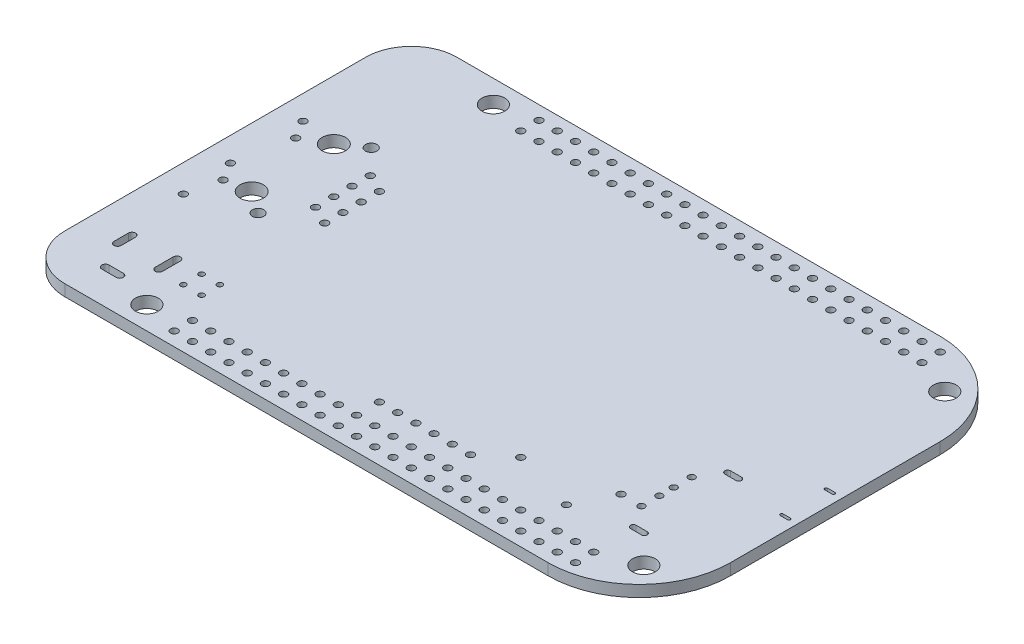
from build123d import *

# Parameters (mm, degrees)
SKETCH2_W                         = 86.36
SKETCH2_H                         = 54.61
MAIN_BOARD_DEPTH                  = 0.79375
SKETCH3_R                         = 1.5875
BOARD_MOUNTING_HOLES_DEPTH        = 2.5875
SKETCH4_R                         = 0.508
SKETCH4_R_2                       = 0.8001
SKETCH4_R_3                       = 1.6256
P5_ETHERNET_CONNECTOR_HOLES_DEPTH = 2.5875
SKETCH5_R                         = 0.45999908
P3_USB_HOST_DEPTH                 = 2.5875
P6_HDMI_DEPTH                     = 2.5875
SKETCH7_R                         = 0.50999898
P9_IDC_EXPANSION_PORT_DEPTH       = 2.5875
SKETCH8_R                         = 0.50999898
P8_IDC_EXPANSION_PORT_DEPTH       = 2.5875
SKETCH9_R                         = 0.508
TP1_TEST_POINT_1_DEPTH            = 2.5875
SKETCH10_R                        = 0.508
TP4_TEST_POINT_4_DEPTH            = 2.5875
SKETCH11_R                        = 0.508
RT1_CAPACITOR_DEPTH               = 2.5875
SKETCH12_R                        = 0.508
J1_DEBUG_PORT_DEPTH               = 2.5875
P1_POWER_PLUG_DEPTH               = 2.5875
SKETCH14_R                        = 0.381
TP6_BATTERY_DEPTH                 = 2.5875
SKETCH15_R                        = 0.381
TP8_BATTERY_DEPTH                 = 2.5875
SKETCH16_R                        = 0.381
TP5_BATTERY_DEPTH                 = 2.5875
SKETCH18_R                        = 0.381
TP7_BATTERY_DEPTH                 = 2.5875
FILLET1_R                         = 6.35
FILLET2_R                         = 12.7


with BuildPart() as part:
    # Sketch2 → Main Board (new body, symmetric)
    with BuildSketch(Plane(origin=(0, 0, 0), x_dir=(1, 0, 0), z_dir=(0, 1, 0))):
        Rectangle(SKETCH2_W, SKETCH2_H)
    extrude(amount=MAIN_BOARD_DEPTH, both=True)

    # Sketch3 → Board Mounting Holes (cut, through all)
    with BuildSketch(Plane.XZ.offset(0.79375)):
        with Locations((37.465, 20.955)):
            Circle(SKETCH3_R)
        with Locations((37.465, -20.955)):
            Circle(SKETCH3_R)
        with Locations((-28.575, -24.13)):
            Circle(SKETCH3_R)
        with Locations((-28.575, 24.13)):
            Circle(SKETCH3_R)
    extrude(amount=-BOARD_MOUNTING_HOLES_DEPTH, mode=Mode.SUBTRACT)

    # Sketch4 → P5 - Ethernet Connector Holes (cut, through all)
    with BuildSketch(Plane.XZ.offset(0.79375)):
        with Locations((-38.3032, 3.7846)):
            Circle(SKETCH4_R)
        with Locations((-39.8272, 1.2446)):
            Circle(SKETCH4_R)
        with Locations((-38.3032, -6.3246)):
            Circle(SKETCH4_R)
        with Locations((-39.8272, -8.8646)):
            Circle(SKETCH4_R)
        with Locations((-28.575, -6.985)):
            Circle(SKETCH4_R)
        with Locations((-28.575, -4.445)):
            Circle(SKETCH4_R)
        with Locations((-28.575, -1.905)):
            Circle(SKETCH4_R)
        with Locations((-28.575, 0.635)):
            Circle(SKETCH4_R)
        with Locations((-26.035, 1.905)):
            Circle(SKETCH4_R)
        with Locations((-26.035, -0.635)):
            Circle(SKETCH4_R)
        with Locations((-26.035, -3.175)):
            Circle(SKETCH4_R)
        with Locations((-26.035, -5.715)):
            Circle(SKETCH4_R)
        with Locations((-31.877, 5.334)):
            Circle(SKETCH4_R_2)
        with Locations((-34.925, 3.175)):
            Circle(SKETCH4_R_3)
        with Locations((-34.925, -8.255)):
            Circle(SKETCH4_R_3)
        with Locations((-31.877, -10.414)):
            Circle(SKETCH4_R_2)
    extrude(amount=-P5_ETHERNET_CONNECTOR_HOLES_DEPTH, mode=Mode.SUBTRACT)

    # Sketch5 → P3 - USB Host (cut, through all)
    with BuildSketch(Plane.XZ.offset(0.79375)):
        with Locations((30.16019114, 13.98778)):
            Circle(SKETCH5_R)
        with Locations((30.16019114, 11.48842)):
            Circle(SKETCH5_R)
        with Locations((30.16019114, 9.4869)):
            Circle(SKETCH5_R)
        with Locations((30.16019114, 6.98754)):
            Circle(SKETCH5_R)
        with BuildLine():
            Line((32.10037014, 17.45453456), (33.64037214, 17.45453456))
            ThreePointArc((33.64037214, 17.45453456), (34.03724714, 17.05765956), (33.64037214, 16.66078456))
            Line((33.64037214, 16.66078456), (32.10037014, 16.66078456))
            ThreePointArc((32.10037014, 16.66078456), (31.70349514, 17.05765956), (32.10037014, 17.45453456))
        make_face()
        with BuildLine():
            Line((32.10037014, 4.31453544), (33.64037214, 4.31453544))
            ThreePointArc((33.64037214, 4.31453544), (34.03724714, 3.91766044), (33.64037214, 3.52078544))
            Line((33.64037214, 3.52078544), (32.10037014, 3.52078544))
            ThreePointArc((32.10037014, 3.52078544), (31.70349514, 3.91766044), (32.10037014, 4.31453544))
        make_face()
    extrude(amount=-P3_USB_HOST_DEPTH, mode=Mode.SUBTRACT)

    # Sketch6 → P6 - HDMI (cut, through all)
    with BuildSketch(Plane.XZ.offset(0.79375)):
        with BuildLine():
            Line((40.962072, 5.4575075), (41.978072, 5.4575075))
            ThreePointArc((41.978072, 5.4575075), (42.1765095, 5.25907), (41.978072, 5.0606325))
            Line((41.978072, 5.0606325), (40.962072, 5.0606325))
            ThreePointArc((40.962072, 5.0606325), (40.7636345, 5.25907), (40.962072, 5.4575075))
        make_face()
        with BuildLine():
            Line((40.962072, -0.7426325), (41.978072, -0.7426325))
            ThreePointArc((41.978072, -0.7426325), (42.1765095, -0.94107), (41.978072, -1.1395075))
            Line((41.978072, -1.1395075), (40.962072, -1.1395075))
            ThreePointArc((40.962072, -1.1395075), (40.7636345, -0.94107), (40.962072, -0.7426325))
        make_face()
    extrude(amount=-P6_HDMI_DEPTH, mode=Mode.SUBTRACT)

    # Sketch7 → P9 - IDC Expansion Port (cut, through all)
    with BuildSketch(Plane.XZ.offset(0.79375)):
        with Locations((32.385, 25.4)):
            Circle(SKETCH7_R)
        with Locations((29.845, 25.4)):
            Circle(SKETCH7_R)
        with Locations((27.305, 25.4)):
            Circle(SKETCH7_R)
        with Locations((24.765, 25.4)):
            Circle(SKETCH7_R)
        with Locations((22.225, 25.4)):
            Circle(SKETCH7_R)
        with Locations((19.685, 25.4)):
            Circle(SKETCH7_R)
        with Locations((17.145, 25.4)):
            Circle(SKETCH7_R)
        with Locations((14.605, 25.4)):
            Circle(SKETCH7_R)
        with Locations((12.065, 25.4)):
            Circle(SKETCH7_R)
        with Locations((9.525, 25.4)):
            Circle(SKETCH7_R)
        with Locations((6.985, 25.4)):
            Circle(SKETCH7_R)
        with Locations((4.445, 25.4)):
            Circle(SKETCH7_R)
        with Locations((1.905, 25.4)):
            Circle(SKETCH7_R)
        with Locations((-0.635, 25.4)):
            Circle(SKETCH7_R)
        with Locations((-3.175, 25.4)):
            Circle(SKETCH7_R)
        with Locations((-5.715, 25.4)):
            Circle(SKETCH7_R)
        with Locations((-8.255, 25.4)):
            Circle(SKETCH7_R)
        with Locations((-10.795, 25.4)):
            Circle(SKETCH7_R)
        with Locations((-13.335, 25.4)):
            Circle(SKETCH7_R)
        with Locations((-15.875, 25.4)):
            Circle(SKETCH7_R)
        with Locations((-18.415, 25.4)):
            Circle(SKETCH7_R)
        with Locations((-20.955, 25.4)):
            Circle(SKETCH7_R)
        with Locations((-23.495, 25.4)):
            Circle(SKETCH7_R)
        with Locations((29.845, 22.86)):
            Circle(SKETCH7_R)
        with Locations((27.305, 22.86)):
            Circle(SKETCH7_R)
        with Locations((24.765, 22.86)):
            Circle(SKETCH7_R)
        with Locations((22.225, 22.86)):
            Circle(SKETCH7_R)
        with Locations((19.685, 22.86)):
            Circle(SKETCH7_R)
        with Locations((17.145, 22.86)):
            Circle(SKETCH7_R)
        with Locations((14.605, 22.86)):
            Circle(SKETCH7_R)
        with Locations((12.065, 22.86)):
            Circle(SKETCH7_R)
        with Locations((9.525, 22.86)):
            Circle(SKETCH7_R)
        with Locations((6.985, 22.86)):
            Circle(SKETCH7_R)
        with Locations((4.445, 22.86)):
            Circle(SKETCH7_R)
        with Locations((1.905, 22.86)):
            Circle(SKETCH7_R)
        with Locations((-0.635, 22.86)):
            Circle(SKETCH7_R)
        with Locations((-3.175, 22.86)):
            Circle(SKETCH7_R)
        with Locations((-5.715, 22.86)):
            Circle(SKETCH7_R)
        with Locations((-8.255, 22.86)):
            Circle(SKETCH7_R)
        with Locations((-10.795, 22.86)):
            Circle(SKETCH7_R)
        with Locations((-13.335, 22.86)):
            Circle(SKETCH7_R)
        with Locations((-15.875, 22.86)):
            Circle(SKETCH7_R)
        with Locations((-18.415, 22.86)):
            Circle(SKETCH7_R)
        with Locations((-20.955, 22.86)):
            Circle(SKETCH7_R)
        with Locations((-23.495, 22.86)):
            Circle(SKETCH7_R)
        with Locations((32.385, 22.86)):
            Circle(SKETCH7_R)
    extrude(amount=-P9_IDC_EXPANSION_PORT_DEPTH, mode=Mode.SUBTRACT)

    # Sketch8 → P8 - IDC Expansion Port (cut, through all)
    with BuildSketch(Plane.XZ.offset(0.79375)):
        with Locations((32.385, -22.86)):
            Circle(SKETCH8_R)
        with Locations((29.845, -22.86)):
            Circle(SKETCH8_R)
        with Locations((27.305, -22.86)):
            Circle(SKETCH8_R)
        with Locations((24.765, -22.86)):
            Circle(SKETCH8_R)
        with Locations((22.225, -22.86)):
            Circle(SKETCH8_R)
        with Locations((19.685, -22.86)):
            Circle(SKETCH8_R)
        with Locations((17.145, -22.86)):
            Circle(SKETCH8_R)
        with Locations((14.605, -22.86)):
            Circle(SKETCH8_R)
        with Locations((12.065, -22.86)):
            Circle(SKETCH8_R)
        with Locations((9.525, -22.86)):
            Circle(SKETCH8_R)
        with Locations((6.985, -22.86)):
            Circle(SKETCH8_R)
        with Locations((4.445, -22.86)):
            Circle(SKETCH8_R)
        with Locations((1.905, -22.86)):
            Circle(SKETCH8_R)
        with Locations((-0.635, -22.86)):
            Circle(SKETCH8_R)
        with Locations((-3.175, -22.86)):
            Circle(SKETCH8_R)
        with Locations((-5.715, -22.86)):
            Circle(SKETCH8_R)
        with Locations((-8.255, -22.86)):
            Circle(SKETCH8_R)
        with Locations((-10.795, -22.86)):
            Circle(SKETCH8_R)
        with Locations((-13.335, -22.86)):
            Circle(SKETCH8_R)
        with Locations((-15.875, -22.86)):
            Circle(SKETCH8_R)
        with Locations((-18.415, -22.86)):
            Circle(SKETCH8_R)
        with Locations((-20.955, -22.86)):
            Circle(SKETCH8_R)
        with Locations((-23.495, -22.86)):
            Circle(SKETCH8_R)
        with Locations((29.845, -25.4)):
            Circle(SKETCH8_R)
        with Locations((27.305, -25.4)):
            Circle(SKETCH8_R)
        with Locations((24.765, -25.4)):
            Circle(SKETCH8_R)
        with Locations((22.225, -25.4)):
            Circle(SKETCH8_R)
        with Locations((19.685, -25.4)):
            Circle(SKETCH8_R)
        with Locations((17.145, -25.4)):
            Circle(SKETCH8_R)
        with Locations((14.605, -25.4)):
            Circle(SKETCH8_R)
        with Locations((12.065, -25.4)):
            Circle(SKETCH8_R)
        with Locations((9.525, -25.4)):
            Circle(SKETCH8_R)
        with Locations((6.985, -25.4)):
            Circle(SKETCH8_R)
        with Locations((4.445, -25.4)):
            Circle(SKETCH8_R)
        with Locations((1.905, -25.4)):
            Circle(SKETCH8_R)
        with Locations((-0.635, -25.4)):
            Circle(SKETCH8_R)
        with Locations((-3.175, -25.4)):
            Circle(SKETCH8_R)
        with Locations((-5.715, -25.4)):
            Circle(SKETCH8_R)
        with Locations((-8.255, -25.4)):
            Circle(SKETCH8_R)
        with Locations((-10.795, -25.4)):
            Circle(SKETCH8_R)
        with Locations((-13.335, -25.4)):
            Circle(SKETCH8_R)
        with Locations((-15.875, -25.4)):
            Circle(SKETCH8_R)
        with Locations((-18.415, -25.4)):
            Circle(SKETCH8_R)
        with Locations((-20.955, -25.4)):
            Circle(SKETCH8_R)
        with Locations((-23.495, -25.4)):
            Circle(SKETCH8_R)
        with Locations((32.385, -25.4)):
            Circle(SKETCH8_R)
    extrude(amount=-P8_IDC_EXPANSION_PORT_DEPTH, mode=Mode.SUBTRACT)

    # Sketch9 → TP1 - Test Point 1 (cut, through all)
    with BuildSketch(Plane.XZ.offset(0.79375)):
        with Locations((15.875, 16.51)):
            Circle(SKETCH9_R)
    extrude(amount=-TP1_TEST_POINT_1_DEPTH, mode=Mode.SUBTRACT)

    # Sketch10 → TP4 - Test Point 4 (cut, through all)
    with BuildSketch(Plane.XZ.offset(0.79375)):
        with Locations((-39.37, 8.255)):
            Circle(SKETCH10_R)
    extrude(amount=-TP4_TEST_POINT_4_DEPTH, mode=Mode.SUBTRACT)

    # Sketch11 → RT1 - Capacitor (cut, through all)
    with BuildSketch(Plane.XZ.offset(0.79375)):
        with Locations((27.305, 13.97)):
            Circle(SKETCH11_R)
        with Locations((24.765, 19.05)):
            Circle(SKETCH11_R)
    extrude(amount=-RT1_CAPACITOR_DEPTH, mode=Mode.SUBTRACT)

    # Sketch12 → J1 - Debug Port (cut, through all)
    with BuildSketch(Plane.XZ.offset(0.79375)):
        with Locations((12.065, 19.685)):
            Circle(SKETCH12_R)
        with Locations((9.525, 19.685)):
            Circle(SKETCH12_R)
        with Locations((6.985, 19.685)):
            Circle(SKETCH12_R)
        with Locations((4.445, 19.685)):
            Circle(SKETCH12_R)
        with Locations((1.905, 19.685)):
            Circle(SKETCH12_R)
        with Locations((-0.635, 19.685)):
            Circle(SKETCH12_R)
    extrude(amount=-J1_DEBUG_PORT_DEPTH, mode=Mode.SUBTRACT)

    # Sketch13 → P1 - Power Plug (cut, through all)
    with BuildSketch(Plane.XZ.offset(0.79375)):
        with BuildLine():
            Line((-31.50362, 19.03000004), (-31.50362, 16.52999996))
            ThreePointArc((-31.50362, 16.52999996), (-32.004, 16.02961996), (-32.50438, 16.52999996))
            Line((-32.50438, 16.52999996), (-32.50438, 19.03000004))
            ThreePointArc((-32.50438, 19.03000004), (-32.004, 19.53038004), (-31.50362, 19.03000004))
        make_face()
        with BuildLine():
            Line((-38.498399, 16.77999946), (-38.498399, 18.78000054))
            ThreePointArc((-38.498399, 18.78000054), (-37.9984, 19.27999954), (-37.498401, 18.78000054))
            Line((-37.498401, 18.78000054), (-37.498401, 16.77999946))
            ThreePointArc((-37.498401, 16.77999946), (-37.9984, 16.28000046), (-38.498399, 16.77999946))
        make_face()
        with BuildLine():
            Line((-36.00120054, 22.97938), (-34.00119946, 22.97938))
            ThreePointArc((-34.00119946, 22.97938), (-33.50081946, 22.479), (-34.00119946, 21.97862))
            Line((-34.00119946, 21.97862), (-36.00120054, 21.97862))
            ThreePointArc((-36.00120054, 21.97862), (-36.50158054, 22.479), (-36.00120054, 22.97938))
        make_face()
    extrude(amount=-P1_POWER_PLUG_DEPTH, mode=Mode.SUBTRACT)

    # Sketch14 → TP6 - BATTERY (cut, through all)
    with BuildSketch(Plane.XZ.offset(0.79375)):
        with Locations((-28.448, 19.177)):
            Circle(SKETCH14_R)
    extrude(amount=-TP6_BATTERY_DEPTH, mode=Mode.SUBTRACT)

    # Sketch15 → TP8 - BATTERY (cut, through all)
    with BuildSketch(Plane.XZ.offset(0.79375)):
        with Locations((-25.908, 19.177)):
            Circle(SKETCH15_R)
    extrude(amount=-TP8_BATTERY_DEPTH, mode=Mode.SUBTRACT)

    # Sketch16 → TP5 - BATTERY (cut, through all)
    with BuildSketch(Plane.XZ.offset(0.79375)):
        with Locations((-28.448, 16.637)):
            Circle(SKETCH16_R)
    extrude(amount=-TP5_BATTERY_DEPTH, mode=Mode.SUBTRACT)

    # Sketch18 → TP7 - BATTERY (cut, through all)
    with BuildSketch(Plane.XZ.offset(0.79375)):
        with Locations((-25.908, 16.637)):
            Circle(SKETCH18_R)
    extrude(amount=-TP7_BATTERY_DEPTH, mode=Mode.SUBTRACT)

    # Fillet1
    fillet1_edges = [part.edges().sort_by_distance(p)[0] for p in [
        (-43.18, 0, 27.305),
        (-43.18, 0, -27.305),
    ]]
    fillet(fillet1_edges, radius=FILLET1_R)

    # Fillet2
    fillet2_edges = [part.edges().sort_by_distance(p)[0] for p in [
        (43.18, 0, 27.305),
        (43.18, 0, -27.305),
    ]]
    fillet(fillet2_edges, radius=FILLET2_R)


solid = part.part
